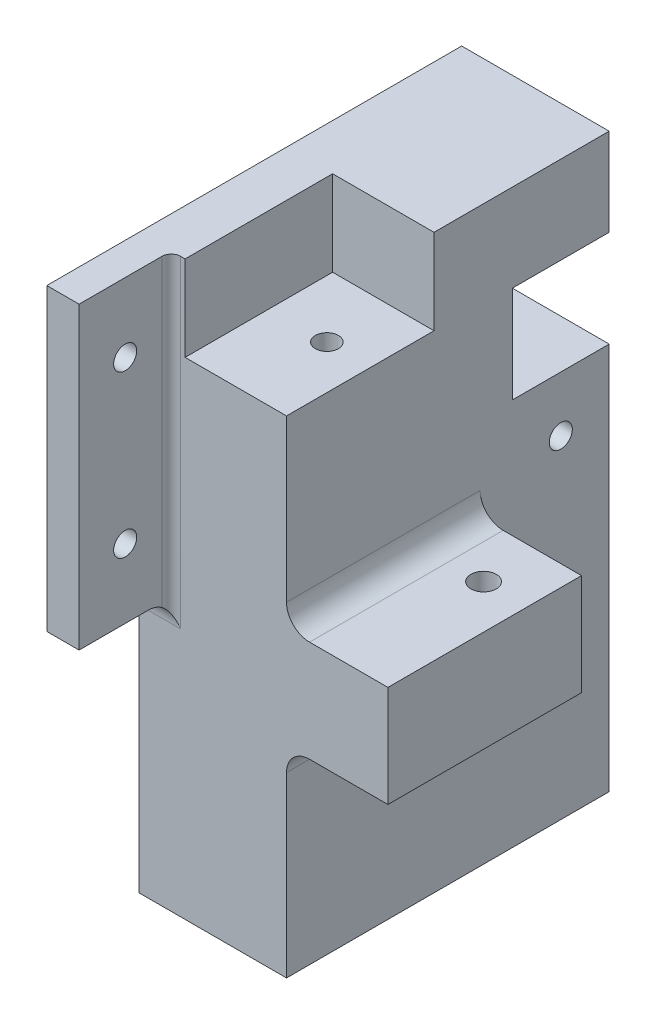
from build123d import *

# Parameters (mm, degrees)
SKETCH1_W                = 32
SKETCH1_H                = 70
BOSS_EXTRUDE1_DEPTH      = 40
BOSS_EXTRUDE1_DEPTH_BACK = 84.1
SKETCH2_W                = 21
SKETCH2_H                = 21
CUT_EXTRUDE1_DEPTH       = 17
CUT_EXTRUDE1_DEPTH_BACK  = 17
CUT_EXTRUDE2_START       = -18.5
SKETCH3_W                = 22
SKETCH3_H                = 32
CUT_EXTRUDE2_DEPTH       = 18.5
SKETCH4_W                = 42
SKETCH4_H                = 22
BOSS_EXTRUDE2_DEPTH      = 22
SKETCH5_R                = 2.75
CUT_EXTRUDE3_DEPTH       = 66.6
SKETCH6_W                = 7
SKETCH6_H                = 65
BOSS_EXTRUDE3_DEPTH      = 20
SKETCH7_R                = 2.5
CUT_EXTRUDE4_DEPTH       = 17
CUT_EXTRUDE4_DEPTH_BACK  = 39
SKETCH8_R                = 2.5
CUT_EXTRUDE5_DEPTH       = 8
FILLET1_R                = 2
FILLET2_R                = 5
SKETCH9_R                = 2.5
CUT_EXTRUDE6_DEPTH       = 47.45


with BuildPart() as part:
    # Sketch1 → Boss-Extrude1 (new body, two sides)
    with BuildSketch(Plane(origin=(0, 0, 0), x_dir=(1, 0, 0), z_dir=(0, 1, 0))) as boss_extrude1_sk:
        Rectangle(SKETCH1_W, SKETCH1_H)
    extrude(amount=BOSS_EXTRUDE1_DEPTH)
    extrude(boss_extrude1_sk.sketch, amount=-BOSS_EXTRUDE1_DEPTH_BACK)

    # Sketch2 → Cut-Extrude1 (cut, two sides)
    with BuildSketch(Plane(origin=(0, 0, 0), x_dir=(0, 0, -1), z_dir=(1, 0, 0))) as cut_extrude1_sk:
        with Locations((24.5, 10.5)):
            Rectangle(SKETCH2_W, SKETCH2_H)
    extrude(amount=CUT_EXTRUDE1_DEPTH, mode=Mode.SUBTRACT)
    extrude(cut_extrude1_sk.sketch, amount=-CUT_EXTRUDE1_DEPTH_BACK, mode=Mode.SUBTRACT)

    # Sketch3 → Cut-Extrude2 (cut)
    with BuildSketch(Plane(origin=(0, 40, 0), x_dir=(1, 0, 0), z_dir=(0, 1, 0)).offset(CUT_EXTRUDE2_START)):
        with Locations((5, -19)):
            Rectangle(SKETCH3_W, SKETCH3_H)
    extrude(amount=CUT_EXTRUDE2_DEPTH, mode=Mode.SUBTRACT)

    # Sketch4 → Boss-Extrude2 (add)
    with BuildSketch(Plane(origin=(16, 0, 0), x_dir=(0, 0, -1), z_dir=(1, 0, 0))):
        with Locations((-14, -29.5)):
            Rectangle(SKETCH4_W, SKETCH4_H)
    extrude(amount=BOSS_EXTRUDE2_DEPTH)

    # Sketch5 → Cut-Extrude3 (cut, through all)
    with BuildSketch(Plane(origin=(0, -18.5, 0), x_dir=(1, 0, 0), z_dir=(0, 1, 0))):
        with Locations((28.5, -4.75)):
            Circle(SKETCH5_R)
    extrude(amount=-CUT_EXTRUDE3_DEPTH, mode=Mode.SUBTRACT)

    # Sketch6 → Boss-Extrude3 (add)
    with BuildSketch(Plane.XY.offset(35)):
        with Locations((-12.5, 7.5)):
            Rectangle(SKETCH6_W, SKETCH6_H)
    extrude(amount=BOSS_EXTRUDE3_DEPTH)

    # Sketch7 → Cut-Extrude4 (cut, two sides)
    with BuildSketch(Plane.ZY) as cut_extrude4_sk:
        with Locations((-24.5, -12)):
            Circle(SKETCH7_R)
    extrude(amount=CUT_EXTRUDE4_DEPTH, mode=Mode.SUBTRACT)
    extrude(cut_extrude4_sk.sketch, amount=-CUT_EXTRUDE4_DEPTH_BACK, mode=Mode.SUBTRACT)

    # Sketch8 → Cut-Extrude5 (cut, through all)
    with BuildSketch(Plane(origin=(-9, 0, 0), x_dir=(0, 0, -1), z_dir=(1, 0, 0))):
        with Locations((-45, 25)):
            Circle(SKETCH8_R)
        with Locations((-45, -10)):
            Circle(SKETCH8_R)
    extrude(amount=-CUT_EXTRUDE5_DEPTH, mode=Mode.SUBTRACT)

    # Fillet1
    fillet1_edges = [part.edges().sort_by_distance(p)[0] for p in [
        (-9, 7.5, 35),
    ]]
    fillet(fillet1_edges, radius=FILLET1_R)

    # Fillet2
    fillet2_edges = [part.edges().sort_by_distance(p)[0] for p in [
        (-12.5, -25, 35),
        (16, -40.5, 14),
        (16, -18.5, 14),
    ]]
    fillet(fillet2_edges, radius=FILLET2_R)

    # Sketch9 → Cut-Extrude6 (cut)
    with BuildSketch(Plane(origin=(0, 21.5, 0), x_dir=(1, 0, 0), z_dir=(0, 1, 0))):
        with Locations((6.5, -16.75)):
            Circle(SKETCH9_R)
    extrude(amount=-CUT_EXTRUDE6_DEPTH, mode=Mode.SUBTRACT)


solid = part.part
